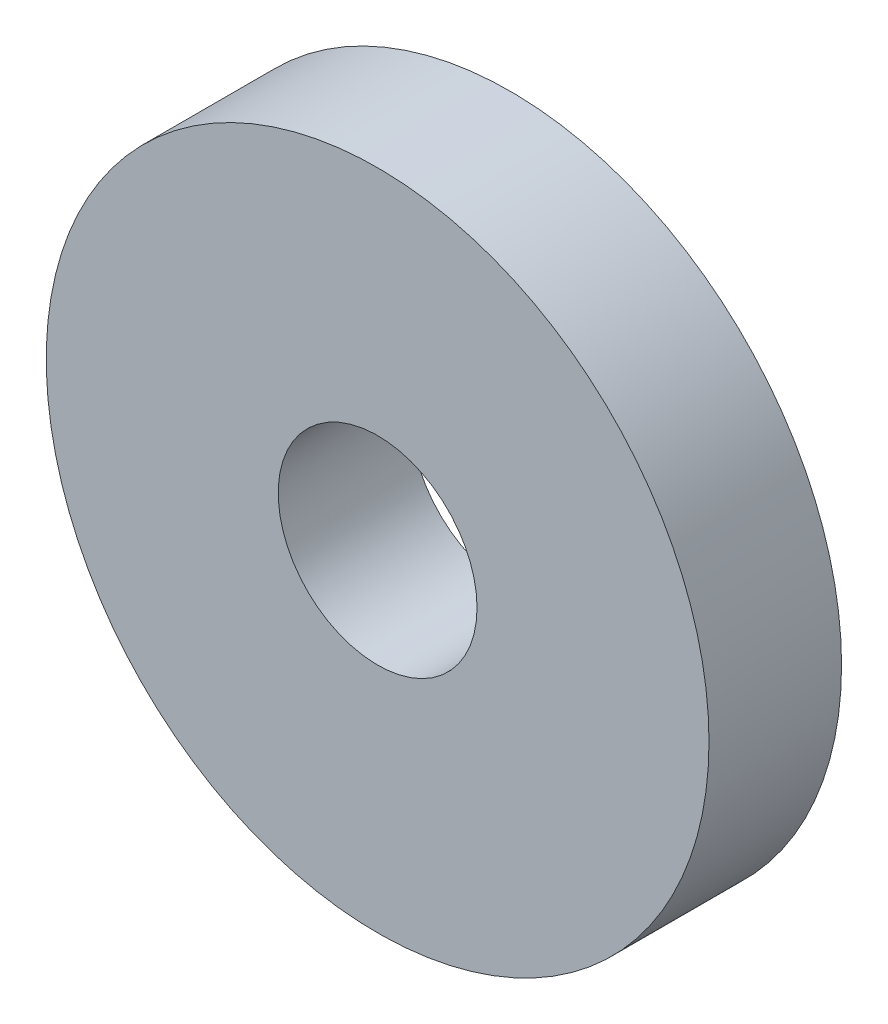
from build123d import *

# Parameters (mm, degrees)
SKETCH_1_W = 4
SKETCH_1_H = 7


with BuildPart() as part:
    # 草图1 → 旋转1 (revolve)
    with BuildSketch(Plane(origin=(0, 0, 0), x_dir=(0, 0, -1), z_dir=(1, 0, 0))):
        with Locations((2, 6.5)):
            Rectangle(SKETCH_1_W, SKETCH_1_H)
    revolve(axis=Axis((0, 0, 0), (0, 0, -1)))


solid = part.part
